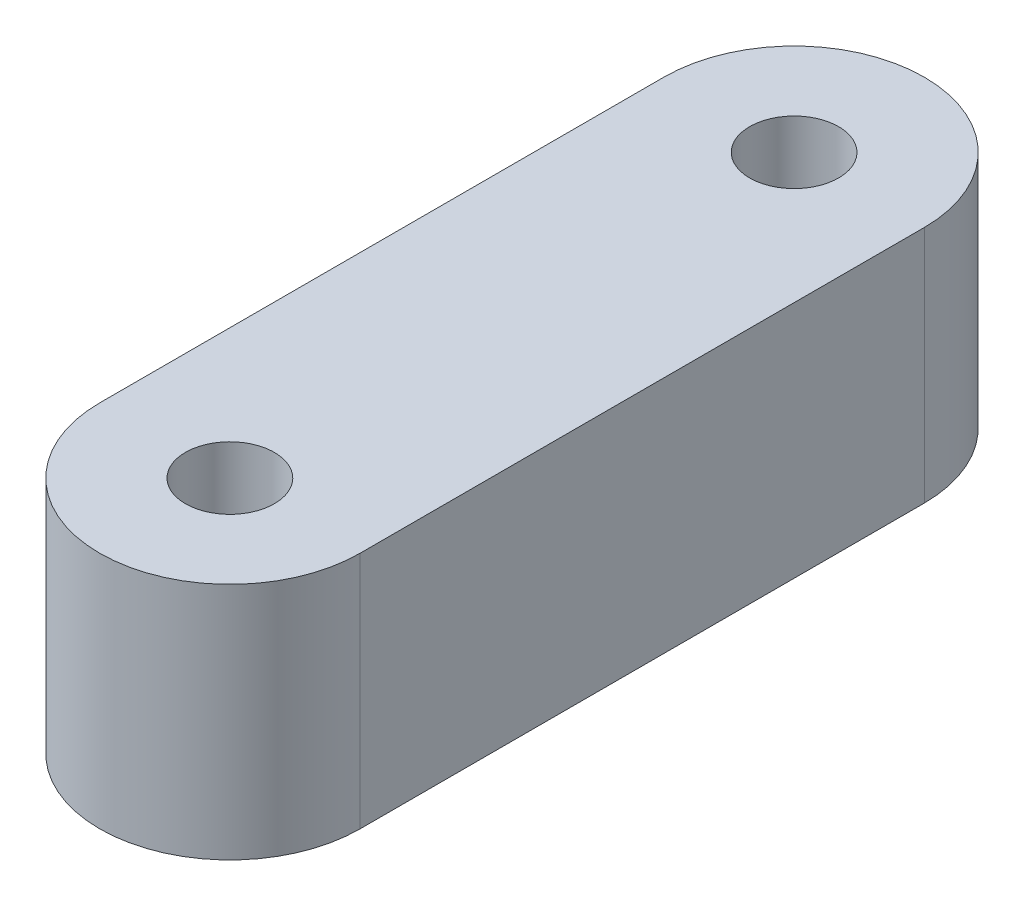
from build123d import *

# Parameters (mm, degrees)
EXTRUDE_1_DEPTH     = 11
SKETCH_2_R          = 2.05
CUT_EXTRUDE_1_DEPTH = 12
SKETCH_3_R          = 3.6
CUT_EXTRUDE_2_DEPTH = 10


with BuildPart() as part:
    # 草图1 → 凸台-拉伸1 (new body)
    with BuildSketch(Plane(origin=(0, 0, 0), x_dir=(1, 0, 0), z_dir=(0, 1, 0))):
        with BuildLine():
            Line((-6, -13), (-6, 13))
            ThreePointArc((-6, 13), (0, 19), (6, 13))
            Line((6, 13), (6, -13))
            ThreePointArc((6, -13), (0, -19), (-6, -13))
        make_face()
    extrude(amount=EXTRUDE_1_DEPTH)

    # 草图2 → 切除-拉伸1 (cut, through all)
    with BuildSketch(Plane(origin=(0, 11, 0), x_dir=(1, 0, 0), z_dir=(0, 1, 0))):
        with Locations((0, 13)):
            Circle(SKETCH_2_R)
        with Locations((0, -13)):
            Circle(SKETCH_2_R)
    extrude(amount=-CUT_EXTRUDE_1_DEPTH, mode=Mode.SUBTRACT)

    # 草图3 → 切除-拉伸2 (cut)
    with BuildSketch(Plane.ZY.offset(6)):
        with Locations((0, 5.5)):
            Circle(SKETCH_3_R)
    extrude(amount=-CUT_EXTRUDE_2_DEPTH, mode=Mode.SUBTRACT)


solid = part.part
